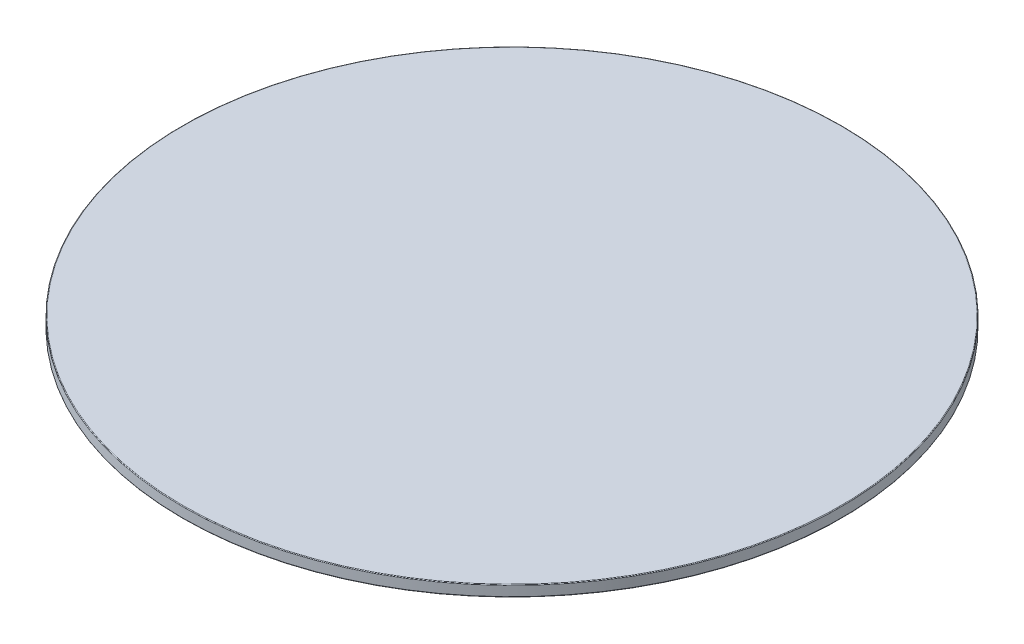
from build123d import *

# Parameters (mm, degrees)
SKETCH1_R           = 150
BOSS_EXTRUDE1_DEPTH = 5
FILLET1_R           = 0.3


with BuildPart() as part:
    # Sketch1 → Boss-Extrude1 (new body)
    with BuildSketch(Plane(origin=(0, 0, 0), x_dir=(1, 0, 0), z_dir=(0, 1, 0))):
        Circle(SKETCH1_R)
    extrude(amount=-BOSS_EXTRUDE1_DEPTH)

    # Fillet1
    fillet1_edges = [part.edges().sort_by_distance(p)[0] for p in [
        (-150, 0, 0),
        (-150, -5, 0),
    ]]
    fillet(fillet1_edges, radius=FILLET1_R)


solid = part.part
